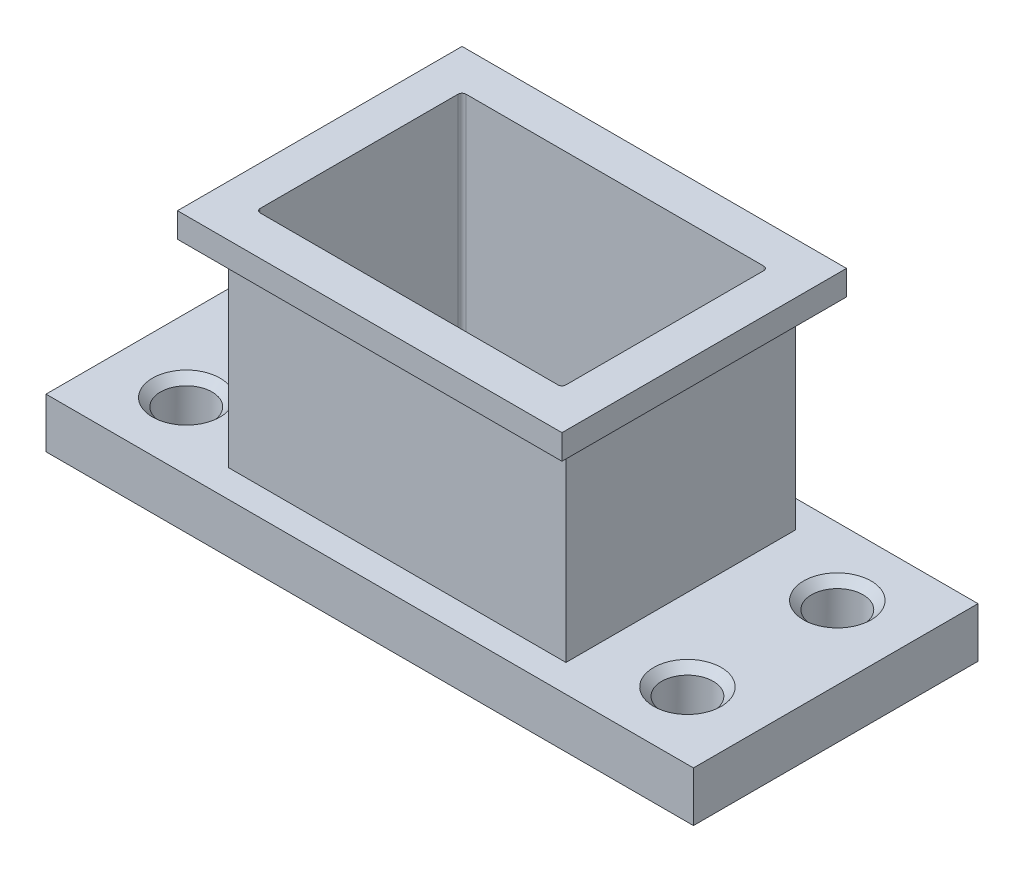
from build123d import *

# Parameters (mm, degrees)
SKETCH1_W          = 41.148
SKETCH1_H          = 18.0848
SKETCH1_W_2        = 19.431
SKETCH1_H_2        = 13.081
EXTRUDE1_DEPTH     = 17.4498
SKETCH2_W          = 8.3566
SKETCH2_H          = 18.0848
CUT_EXTRUDE1_DEPTH = 14.2748
CUT_EXTRUDE2_START = -1.5748
SKETCH3_W          = 24.4348
SKETCH3_H          = 18.0848
SKETCH3_W_2        = 21.4376
SKETCH3_H_2        = 14.5796
CUT_EXTRUDE2_DEPTH = 12.7
SKETCH4_R          = 1.6383
CUT_EXTRUDE3_DEPTH = 4.175
CHAMFER1_SIZE      = 0.508
FILLET1_R          = 0.254
CHAMFER2_SIZE      = 0.508


with BuildPart() as part:
    # Sketch1 → Extrude1 (new body)
    with BuildSketch(Plane(origin=(0, 0, 0), x_dir=(1, 0, 0), z_dir=(0, 1, 0))):
        with Locations((20.574, 9.0424)):
            Rectangle(SKETCH1_W, SKETCH1_H)
        with Locations((20.574, 9.0424)):
            Rectangle(SKETCH1_W_2, SKETCH1_H_2, mode=Mode.SUBTRACT)
    extrude(amount=EXTRUDE1_DEPTH)

    # Sketch2 → Cut-Extrude1 (cut)
    with BuildSketch(Plane(origin=(0, 17.4498, 0), x_dir=(-1, 0, 0), z_dir=(0, 1, 0))):
        with Locations((-4.1783, -9.0424)):
            Rectangle(SKETCH2_W, SKETCH2_H)
        with Locations((-36.9697, -9.0424)):
            Rectangle(SKETCH2_W, SKETCH2_H)
    extrude(amount=-CUT_EXTRUDE1_DEPTH, mode=Mode.SUBTRACT)

    # Sketch3 → Cut-Extrude2 (cut)
    with BuildSketch(Plane(origin=(0, 17.4498, 0), x_dir=(-1, 0, 0), z_dir=(0, 1, 0)).offset(CUT_EXTRUDE2_START)):
        with Locations((-20.574, -9.0424)):
            Rectangle(SKETCH3_W, SKETCH3_H)
        with Locations((-20.574, -9.0424)):
            Rectangle(SKETCH3_W_2, SKETCH3_H_2, mode=Mode.SUBTRACT)
    extrude(amount=-CUT_EXTRUDE2_DEPTH, mode=Mode.SUBTRACT)

    # Sketch4 → Cut-Extrude3 (cut, through all)
    with BuildSketch(Plane(origin=(0, 3.175, 0), x_dir=(-1, 0, 0), z_dir=(0, 1, 0))):
        with Locations(Location((-36.4998, -13.7922, 0), (0, 0, 90))):  # turned: the seam where the file's is
            Circle(SKETCH4_R)
        with Locations(Location((-36.4998, -4.2672, 0), (0, 0, 90))):  # turned: the seam where the file's is
            Circle(SKETCH4_R)
        with Locations(Location((-4.6482, -4.2672, 0), (0, 0, 90))):  # turned: the seam where the file's is
            Circle(SKETCH4_R)
        with Locations(Location((-4.6482, -13.7922, 0), (0, 0, 90))):  # turned: the seam where the file's is
            Circle(SKETCH4_R)
    extrude(amount=-CUT_EXTRUDE3_DEPTH, mode=Mode.SUBTRACT)

    # Chamfer1
    chamfer1_edges = [part.edges().sort_by_distance(p)[0] for p in [
        (36.4998, 3.175, -15.4305),
        (36.4998, 3.175, -5.9055),
        (4.6482, 3.175, -5.9055),
        (4.6482, 3.175, -15.4305),
    ]]
    chamfer(chamfer1_edges, length=CHAMFER1_SIZE)

    # Fillet1
    fillet1_edges = [part.edges().sort_by_distance(p)[0] for p in [
        (10.8585, 8.7249, -15.5829),
        (10.8585, 8.7249, -2.5019),
        (30.2895, 8.7249, -2.5019),
        (30.2895, 8.7249, -15.5829),
    ]]
    fillet(fillet1_edges, radius=FILLET1_R)

    # Chamfer2
    chamfer2_edges = [part.edges().sort_by_distance(p)[0] for p in [
        (36.4998, 0, -15.4305),
        (36.4998, 0, -5.9055),
        (4.6482, 0, -5.9055),
        (4.6482, 0, -15.4305),
    ]]
    chamfer(chamfer2_edges, length=CHAMFER2_SIZE)


solid = part.part
